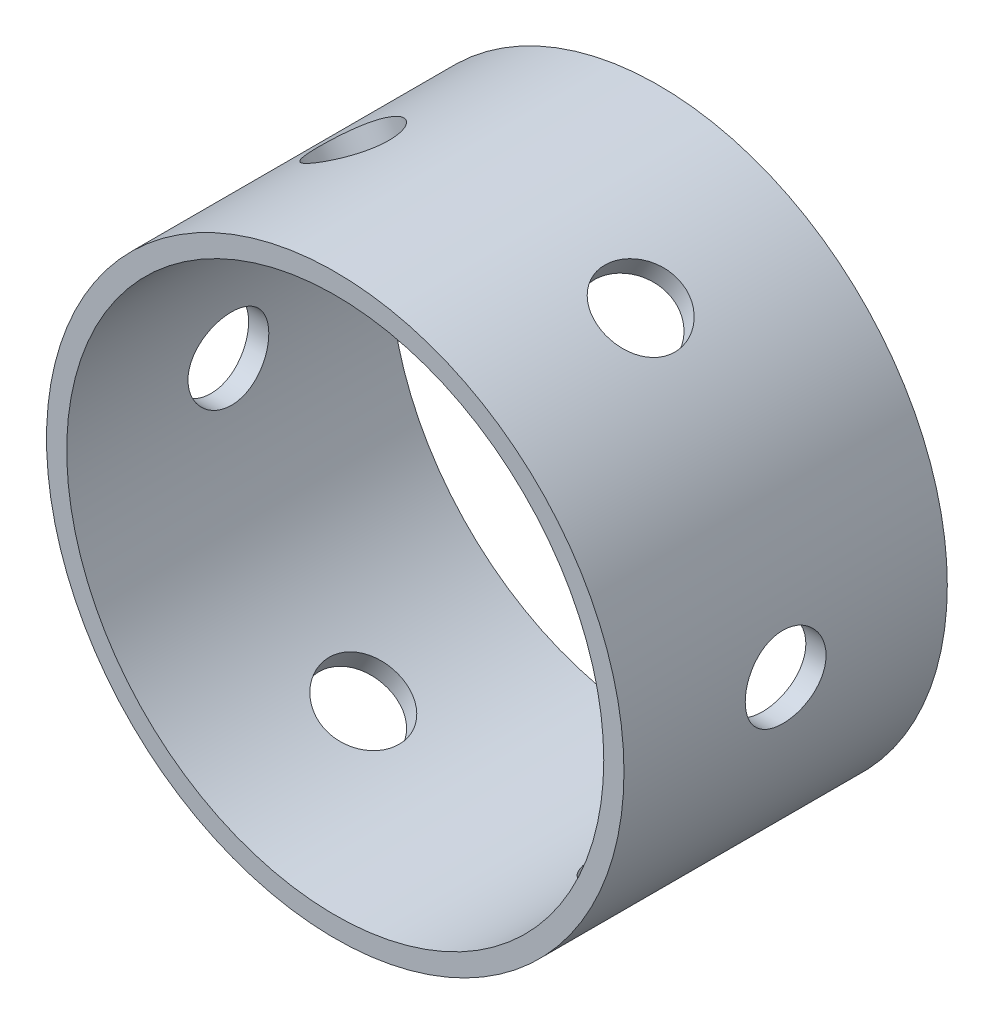
from build123d import *

# Parameters (mm, degrees)
ESBO_O1_R                = 28.575
ESBO_O1_R_2              = 26.575
RESSALTO_EXTRUS_O1_DEPTH = 32
ESBO_O2_R                = 4
CORTE_EXTRUS_O1_DEPTH    = 32
PADR_OCIRCULAR1_COUNT    = 6


with BuildPart() as part:
    # Esboço1 → Ressalto-extrusão1 (new body)
    with BuildSketch(Plane.XY):
        Circle(ESBO_O1_R)
        Circle(ESBO_O1_R_2, mode=Mode.SUBTRACT)
    extrude(amount=RESSALTO_EXTRUS_O1_DEPTH)

    # Esboço2 → Corte-extrusão1 (cut)
    with BuildSketch(Plane(origin=(0, 0, 0), x_dir=(0, 0, -1), z_dir=(1, 0, 0))):
        with Locations((-16, 0)):
            Circle(ESBO_O2_R)
    corte_extrus_o1 = extrude(amount=-CORTE_EXTRUS_O1_DEPTH, mode=Mode.SUBTRACT)

    # PadrãoCircular1: Corte-extrusão1 ×6 about axis
    padr_ocircular1_axis = Axis((0, 0, 32), (0, 0, -1))
    for i in range(1, PADR_OCIRCULAR1_COUNT):
        add(corte_extrus_o1.rotate(padr_ocircular1_axis, i * 360 / PADR_OCIRCULAR1_COUNT), mode=Mode.SUBTRACT)


solid = part.part
